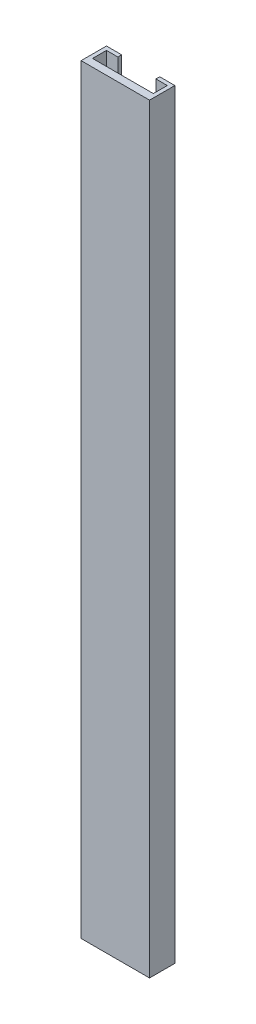
from build123d import *

# Parameters (mm, degrees)
BOSS_EXTRU_1_DEPTH = 300


with BuildPart() as part:
    # Esquisse1 → Boss.-Extru.1 (new body)
    with BuildSketch(Plane(origin=(0, 0, 0), x_dir=(1, 0, 0), z_dir=(0, 1, 0))):
        Polygon((-13.5, 0), (13.5, 0), (13.5, 10), (7.5, 10), (7.5, 8.5), (12, 8.5), (12, 3), (-12, 3), (-12, 8.5), (-7.5, 8.5), (-7.5, 10), (-13.5, 10), align=None)
    extrude(amount=BOSS_EXTRU_1_DEPTH)


solid = part.part
